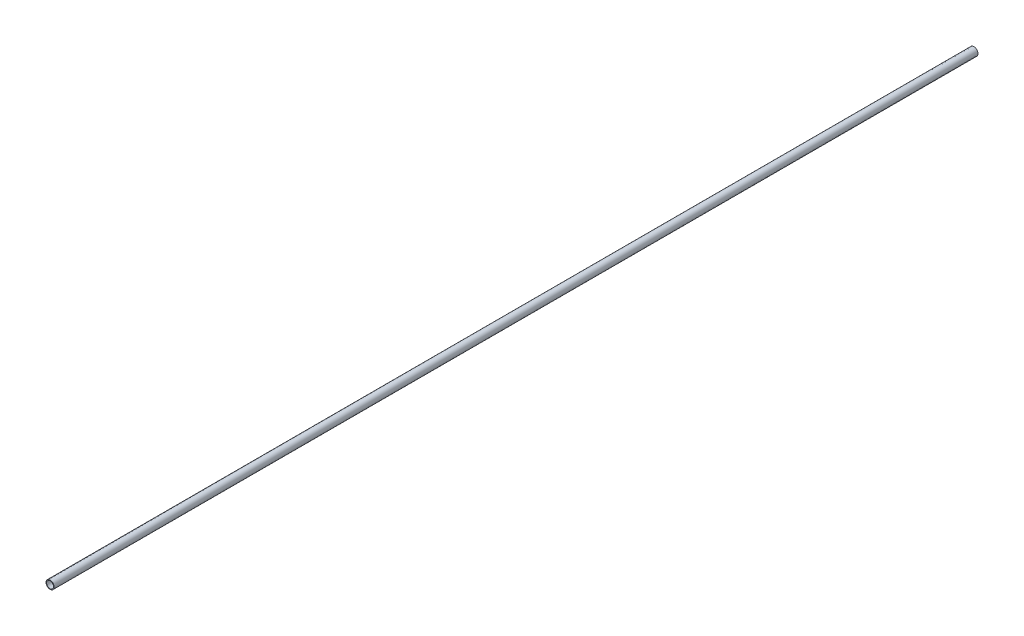
from build123d import *

# Parameters (mm, degrees)
PIPESKETCH_R    = 24.13
PIPESKETCH_R_2  = 20.447
EXTRUSION_DEPTH = 5486.4


with BuildPart() as part:
    # PipeSketch → Extrusion (new body)
    with BuildSketch(Plane.XY):
        Circle(PIPESKETCH_R)
        Circle(PIPESKETCH_R_2, mode=Mode.SUBTRACT)
    extrude(amount=EXTRUSION_DEPTH)


solid = part.part
